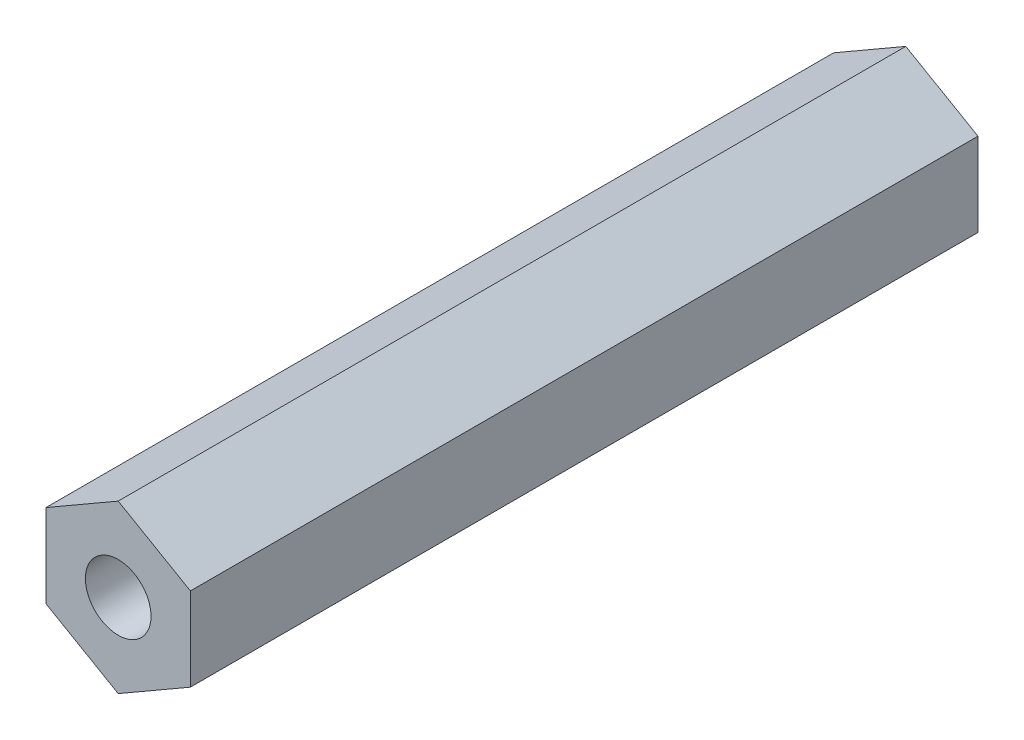
from build123d import *

# Parameters (mm, degrees)
BOSS_EXTRU_1_DEPTH                            = 30
TROU_POUR_TARAUDAGE_POUR_TROU_TARAUD_M3_D     = 2.5
TROU_POUR_TARAUDAGE_POUR_TROU_TARAUD_M3_DEPTH = 7
TROU_POUR_TARAUDAGE_POUR_TROU_TARAUD_M3_TIP   = 0.751075774
TROU_POUR_TARAUDAGE_POUR_TROU_TARAUD_2_D      = 2.5
TROU_POUR_TARAUDAGE_POUR_TROU_TARAUD_2_DEPTH  = 7
TROU_POUR_TARAUDAGE_POUR_TROU_TARAUD_2_TIP    = 0.751075774


with BuildPart() as part:
    # Esquisse1 → Boss.-Extru.1 (new body)
    with BuildSketch(Plane.XY):
        Polygon((0, -3.175426481), (2.75, -1.58771324), (2.75, 1.58771324), (0, 3.175426481), (-2.75, 1.58771324), (-2.75, -1.58771324), align=None)
    extrude(amount=BOSS_EXTRU_1_DEPTH)

    # Trou pour taraudage pour trou taraud_ M3
    with Locations(Plane.XY.offset(30)):
        with Locations((0, 0)):
            Hole(TROU_POUR_TARAUDAGE_POUR_TROU_TARAUD_M3_D / 2, depth=TROU_POUR_TARAUDAGE_POUR_TROU_TARAUD_M3_DEPTH)
            with Locations((0, 0, -(TROU_POUR_TARAUDAGE_POUR_TROU_TARAUD_M3_DEPTH + TROU_POUR_TARAUDAGE_POUR_TROU_TARAUD_M3_TIP / 2))):  # 118° drill point
                Cone(0, TROU_POUR_TARAUDAGE_POUR_TROU_TARAUD_M3_D / 2, TROU_POUR_TARAUDAGE_POUR_TROU_TARAUD_M3_TIP, mode=Mode.SUBTRACT)

    # Trou pour taraudage pour trou taraud 2
    with Locations(Plane(origin=(0, 0, 0), x_dir=(-1, 0, 0), z_dir=(0, 0, -1))):
        with Locations((0, 0)):
            Hole(TROU_POUR_TARAUDAGE_POUR_TROU_TARAUD_2_D / 2, depth=TROU_POUR_TARAUDAGE_POUR_TROU_TARAUD_2_DEPTH)
            with Locations((0, 0, -(TROU_POUR_TARAUDAGE_POUR_TROU_TARAUD_2_DEPTH + TROU_POUR_TARAUDAGE_POUR_TROU_TARAUD_2_TIP / 2))):  # 118° drill point
                Cone(0, TROU_POUR_TARAUDAGE_POUR_TROU_TARAUD_2_D / 2, TROU_POUR_TARAUDAGE_POUR_TROU_TARAUD_2_TIP, mode=Mode.SUBTRACT)


solid = part.part
